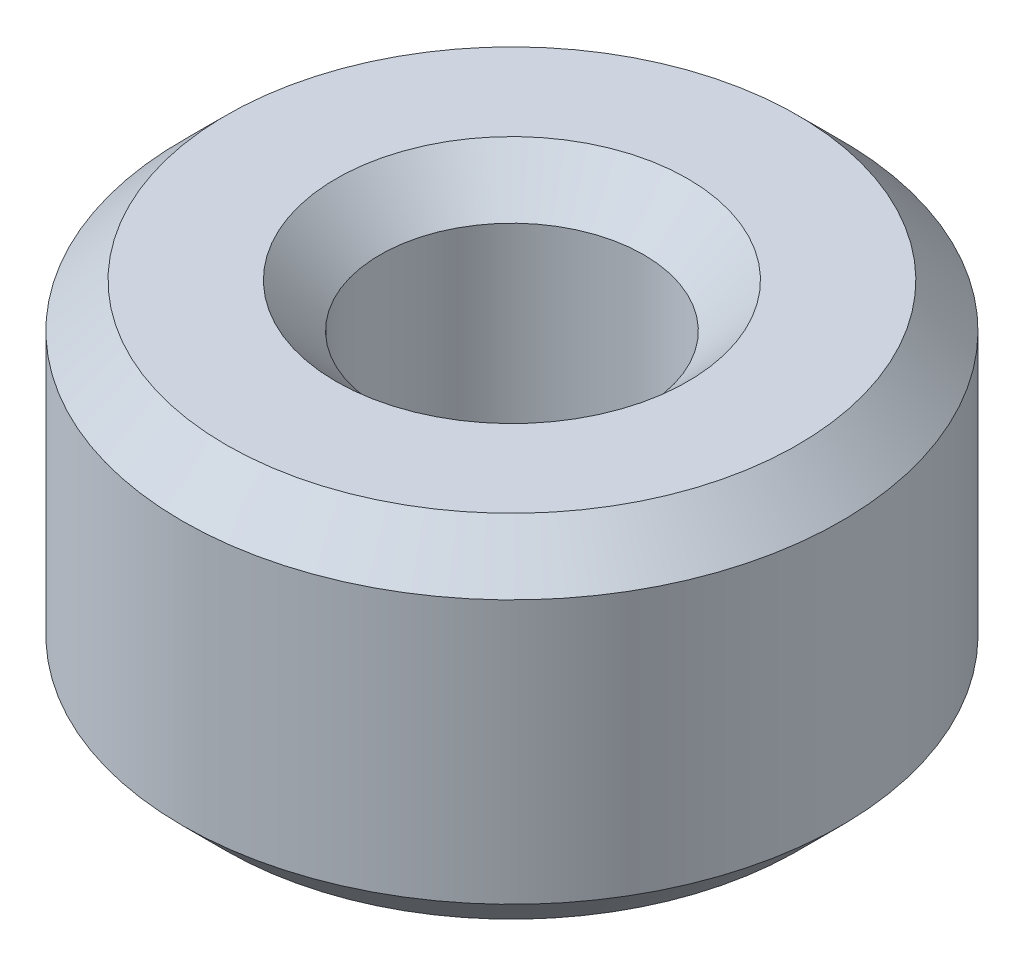
from build123d import *

# Parameters (mm, degrees)
SKETCH1_R           = 7.5
SKETCH1_R_2         = 3
BOSS_EXTRUDE1_DEPTH = 8
CHAMFER1_SIZE       = 1


with BuildPart() as part:
    # Sketch1 → Boss-Extrude1 (new body)
    with BuildSketch(Plane(origin=(0, 0, 0), x_dir=(1, 0, 0), z_dir=(0, 1, 0))):
        Circle(SKETCH1_R)
        Circle(SKETCH1_R_2, mode=Mode.SUBTRACT)
    extrude(amount=BOSS_EXTRUDE1_DEPTH)

    # Chamfer1
    chamfer1_edges = [part.edges().sort_by_distance(p)[0] for p in [
        (-7.5, 0, 0),
        (-7.5, 8, 0),
        (-3, 0, 0),
        (-3, 8, 0),
    ]]
    chamfer(chamfer1_edges, length=CHAMFER1_SIZE)


solid = part.part
